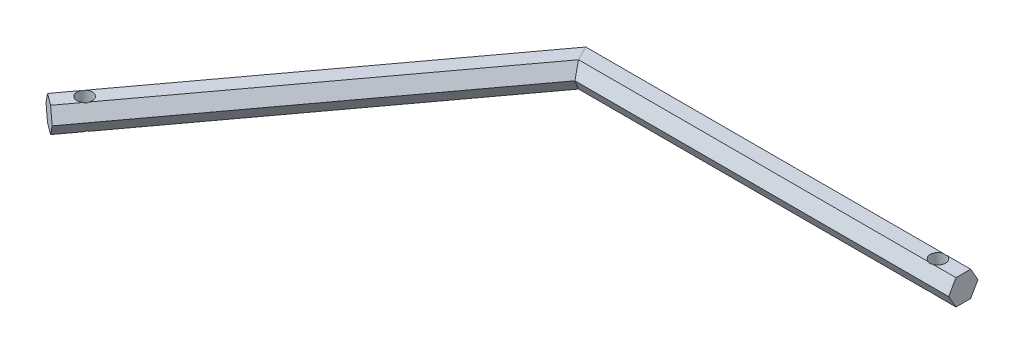
from build123d import *

# Parameters (mm, degrees)
SKETCH4_R          = 3
CUT_EXTRUDE1_DEPTH = 11


with BuildPart() as part:
    # Sweep2: sweep along a path in Sketch1
    with BuildLine(Plane(origin=(0, 0, 0), x_dir=(1, 0, 0), z_dir=(0, 1, 0))) as sweep2_path:
        Line((150, 0), (0, 0))
        Line((0, 0), (-89.223418013, -120.578529093))
    # Sketch2 → Sweep2 (sweep)
    with BuildSketch(Plane(origin=(-89.223418013, 0, 120.578529093), x_dir=(0.803856861, 0, 0.594822787), z_dir=(-0.594822787, 0, 0.803856861))):
        Polygon((2.886751346, -5), (5.773502692, 0), (2.886751346, 5), (-2.886751346, 5), (-5.773502692, 0), (-2.886751346, -5), align=None)
    sweep(path=sweep2_path.line, transition=Transition.RIGHT)

    # Sketch4 → Cut-Extrude1 (cut, through all)
    with BuildSketch(Plane(origin=(0, 5, 0), x_dir=(1, 0, 0), z_dir=(0, 1, 0))):
        with Locations((140, 0)):
            Circle(SKETCH4_R)
    cut_extrude1 = extrude(amount=-CUT_EXTRUDE1_DEPTH, mode=Mode.SUBTRACT)

    # Mirror1: Cut-Extrude1 across plane
    add(cut_extrude1.mirror(Plane(origin=(0, 0, 0), x_dir=(0.450098441, 0, 0.892978943), z_dir=(0.892978943, 0, -0.450098441))), mode=Mode.SUBTRACT)


solid = part.part
